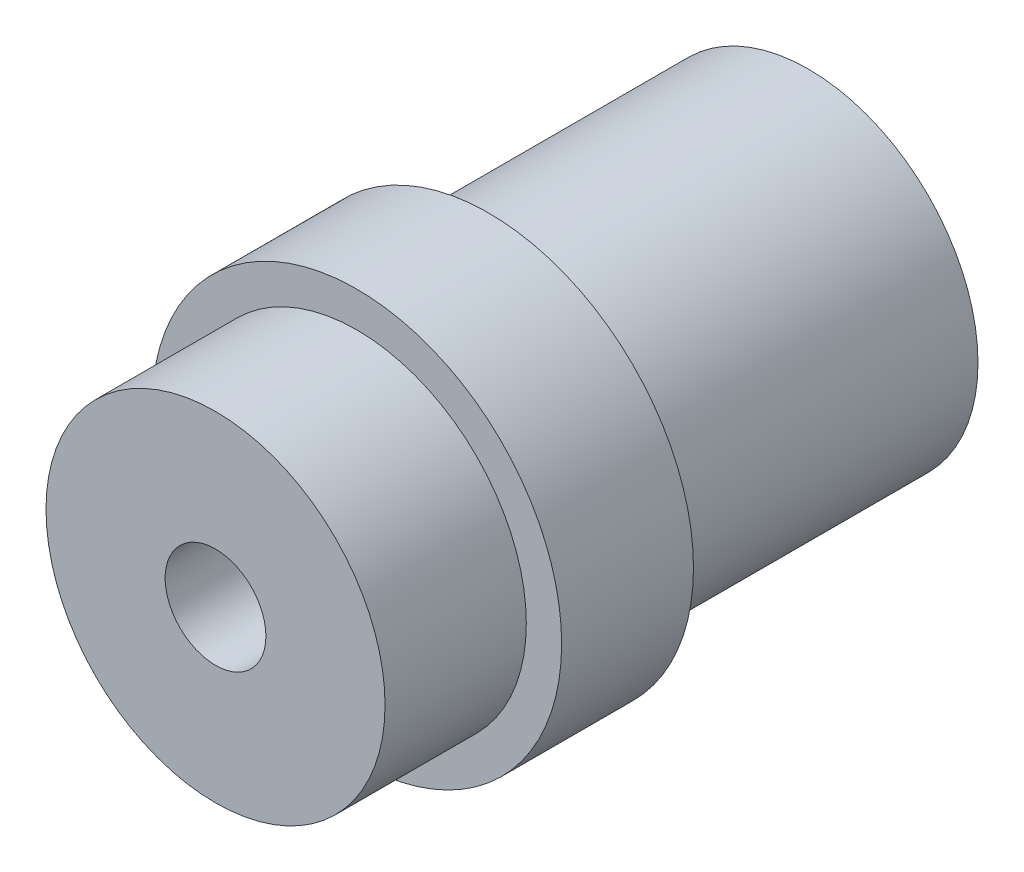
from build123d import *

# Parameters (mm, degrees)
SKETCH1_R           = 9
SKETCH1_R_2         = 2.675
BOSS_EXTRUDE1_DEPTH = 16.98
SKETCH2_R           = 10.875
SKETCH2_R_2         = 2.675
BOSS_EXTRUDE2_DEPTH = 7
SKETCH4_R           = 9
SKETCH4_R_2         = 2.675
BOSS_EXTRUDE3_DEPTH = 7.5


with BuildPart() as part:
    # Sketch1 → Boss-Extrude1 (new body)
    with BuildSketch(Plane.XY):
        Circle(SKETCH1_R)
        Circle(SKETCH1_R_2, mode=Mode.SUBTRACT)
    extrude(amount=BOSS_EXTRUDE1_DEPTH)

    # Sketch2 → Boss-Extrude2 (add)
    with BuildSketch(Plane.XY.offset(16.98)):
        Circle(SKETCH2_R)
        Circle(SKETCH2_R_2, mode=Mode.SUBTRACT)
    extrude(amount=BOSS_EXTRUDE2_DEPTH)

    # Sketch4 → Boss-Extrude3 (add)
    with BuildSketch(Plane.XY.offset(23.98)):
        Circle(SKETCH4_R)
        Circle(SKETCH4_R_2, mode=Mode.SUBTRACT)
    extrude(amount=BOSS_EXTRUDE3_DEPTH)


solid = part.part
